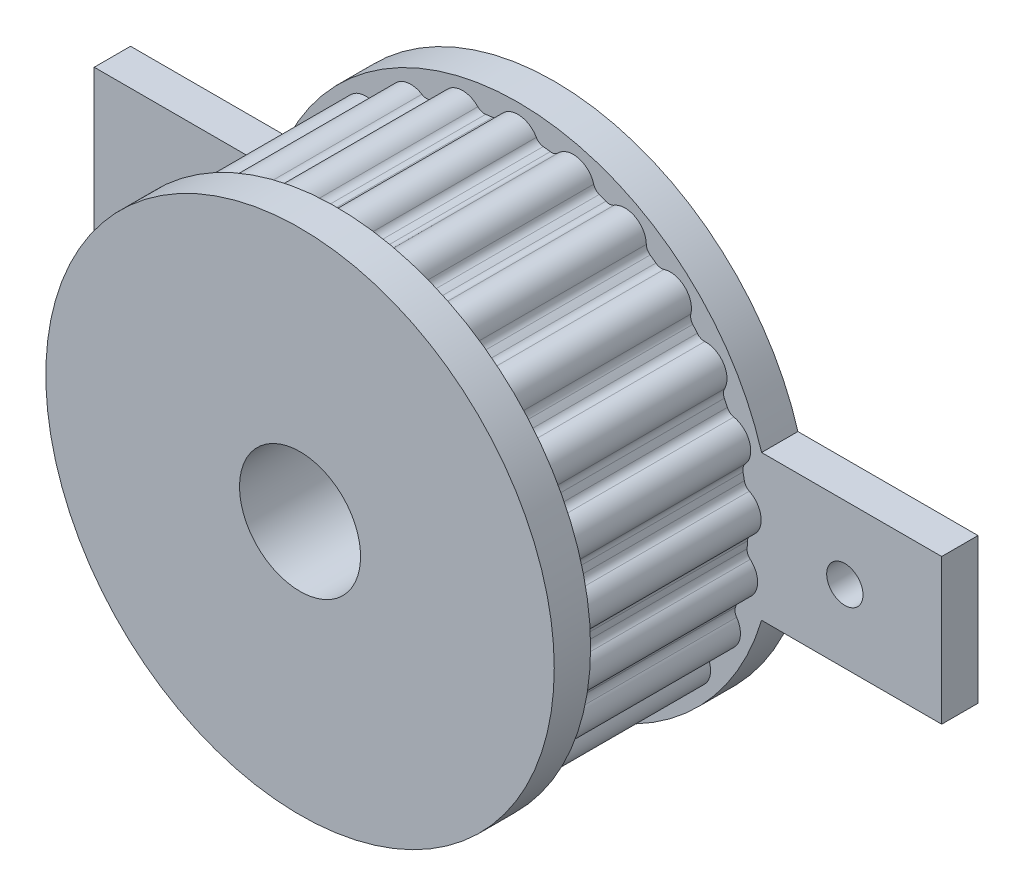
from build123d import *

# Parameters (mm, degrees)
ESQUISSE1_R                        = 21
BOSS_EXTRU_1_DEPTH                 = 21
ESQUISSE2_W                        = 21
ESQUISSE2_H                        = 5
ESQUISSE3_R                        = 28.5
ESQUISSE3_R_2                      = 18.985
ENL_V_MAT_EXTRU_1_DEPTH            = 15
BOSS_EXTRU_2_DEPTH                 = 15
CONG_1_R                           = 0.75
R_P_TITION_CIRCULAIRE1_COUNT       = 25
CONG_1_OF_R_P_TITION_CIRCULAIRE1_R = 0.75
SKETCH2_W                          = 70
SKETCH2_H                          = 12
SKETCH2_R                          = 1.5
SKETCH2_R_2                        = 5
BOSS_EXTRUDE1_DEPTH                = 3


with BuildPart() as part:
    # Esquisse1 → Boss.-Extru.1 (new body)
    with BuildSketch(Plane.XY):
        Circle(ESQUISSE1_R)
    extrude(amount=BOSS_EXTRU_1_DEPTH)

    # Esquisse2 → Enlèvement de matière-Révolution1 (revolve, cut)
    with BuildSketch(Plane(origin=(0, 0, 0), x_dir=(0, 0, -1), z_dir=(1, 0, 0))):
        with Locations((-10.5, 2.5)):
            Rectangle(ESQUISSE2_W, ESQUISSE2_H)
    revolve(axis=Axis((0, 0, 0), (0, 0, 1)), mode=Mode.SUBTRACT)

    # Esquisse3 → Enlèv. mat.-Extru.1 (cut)
    with BuildSketch(Plane.XY.offset(18)):
        Circle(ESQUISSE3_R)
        Circle(ESQUISSE3_R_2, mode=Mode.SUBTRACT)
    extrude(amount=-ENL_V_MAT_EXTRU_1_DEPTH, mode=Mode.SUBTRACT)

    # Esquisse5 → Boss.-Extru.2 (add)
    with BuildSketch(Plane(origin=(0, 0, 18), x_dir=(-1, 0, 0), z_dir=(0, 0, -1))):
        with BuildLine():
            ThreePointArc((-1.666666667, 18.911701331), (0, 18.985), (1.666666667, 18.911701331))
            ThreePointArc((1.666666667, 18.911701331), (0, 20.125), (-1.666666667, 18.911701331))
        make_face()
    boss_extru_2 = extrude(amount=BOSS_EXTRU_2_DEPTH)

    # Congé1
    cong_1_edges = [part.edges().sort_by_distance(p)[0] for p in [
        (1.666666667, 18.911701331, 10.5),
        (-1.666666667, 18.911701331, 10.5),
    ]]
    fillet(cong_1_edges, radius=CONG_1_R)

    # Répétition circulaire1: Boss.-Extru.2 ×25 about axis
    r_p_tition_circulaire1_axis = Axis((0, 0, 0), (0, 0, 1))
    for i in range(1, R_P_TITION_CIRCULAIRE1_COUNT):
        add(boss_extru_2.rotate(r_p_tition_circulaire1_axis, i * 360 / R_P_TITION_CIRCULAIRE1_COUNT))

    # Congé1 of Répétition circulaire1
    cong_1_of_r_p_tition_circulaire1_edges = [part.edges().sort_by_distance(p)[0] for p in [
        (-3.088843601, 18.732038603, 10.5),
        (-6.317454139, 17.903072312, 10.5),
        (-7.650270466, 17.375372997, 10.5),
        (-10.571292733, 15.769527417, 10.5),
        (-11.731002702, 14.926948804, 10.5),
        (-14.160898126, 12.645125118, 10.5),
        (-15.074632894, 11.540609521, 10.5),
        (-16.860722211, 8.726183102, 10.5),
        (-17.471068461, 7.429131298, 10.5),
        (-18.501125109, 4.25894291, 10.5),
        (-18.769732542, 2.850853432, 10.5),
        (-18.979034274, -0.475902329, 10.5),
        (-18.889025298, -1.906554039, 10.5),
        (-18.264420916, -5.180844874, 10.5),
        (-17.821451125, -6.544165707, 10.5),
        (-16.40218682, -9.560255882, 10.5),
        (-15.634089635, -10.770583377, 10.5),
        (-13.509343002, -13.338960853, 10.5),
        (-12.464380795, -14.320245682, 10.5),
        (-9.767657481, -16.279529856, 10.5),
        (-8.511489069, -16.970114284, 10.5),
        (-5.412234116, -18.197196127, 10.5),
        (-4.023789182, -18.553688194, 10.5),
        (-0.716740178, -18.97146564, 10.5),
        (0.716740178, -18.97146564, 10.5),
        (4.023789182, -18.553688194, 10.5),
        (5.412234116, -18.197196127, 10.5),
        (8.511489069, -16.970114284, 10.5),
        (9.767657481, -16.279529856, 10.5),
        (12.464380795, -14.320245682, 10.5),
        (13.509343002, -13.338960853, 10.5),
        (15.634089635, -10.770583377, 10.5),
        (16.40218682, -9.560255882, 10.5),
        (17.821451125, -6.544165707, 10.5),
        (18.264420916, -5.180844874, 10.5),
        (18.889025298, -1.906554039, 10.5),
        (18.979034274, -0.475902329, 10.5),
        (18.769732542, 2.850853432, 10.5),
        (18.501125109, 4.25894291, 10.5),
        (17.471068461, 7.429131298, 10.5),
        (16.860722211, 8.726183102, 10.5),
        (15.074632894, 11.540609521, 10.5),
        (14.160898126, 12.645125118, 10.5),
        (11.731002702, 14.926948804, 10.5),
        (10.571292733, 15.769527417, 10.5),
        (7.650270466, 17.375372997, 10.5),
        (6.317454139, 17.903072312, 10.5),
        (3.088843601, 18.732038603, 10.5),
    ]]
    fillet(cong_1_of_r_p_tition_circulaire1_edges, radius=CONG_1_OF_R_P_TITION_CIRCULAIRE1_R)

    # Sketch2 → Boss-Extrude1 (add)
    with BuildSketch(Plane(origin=(0, 0, 0), x_dir=(-1, 0, 0), z_dir=(0, 0, -1))):
        Rectangle(SKETCH2_W, SKETCH2_H)
        with Locations((-27, 0)):
            Circle(SKETCH2_R, mode=Mode.SUBTRACT)
        with Locations((27, 0)):
            Circle(SKETCH2_R, mode=Mode.SUBTRACT)
        Circle(SKETCH2_R_2, mode=Mode.SUBTRACT)
    extrude(amount=-BOSS_EXTRUDE1_DEPTH)


solid = part.part
